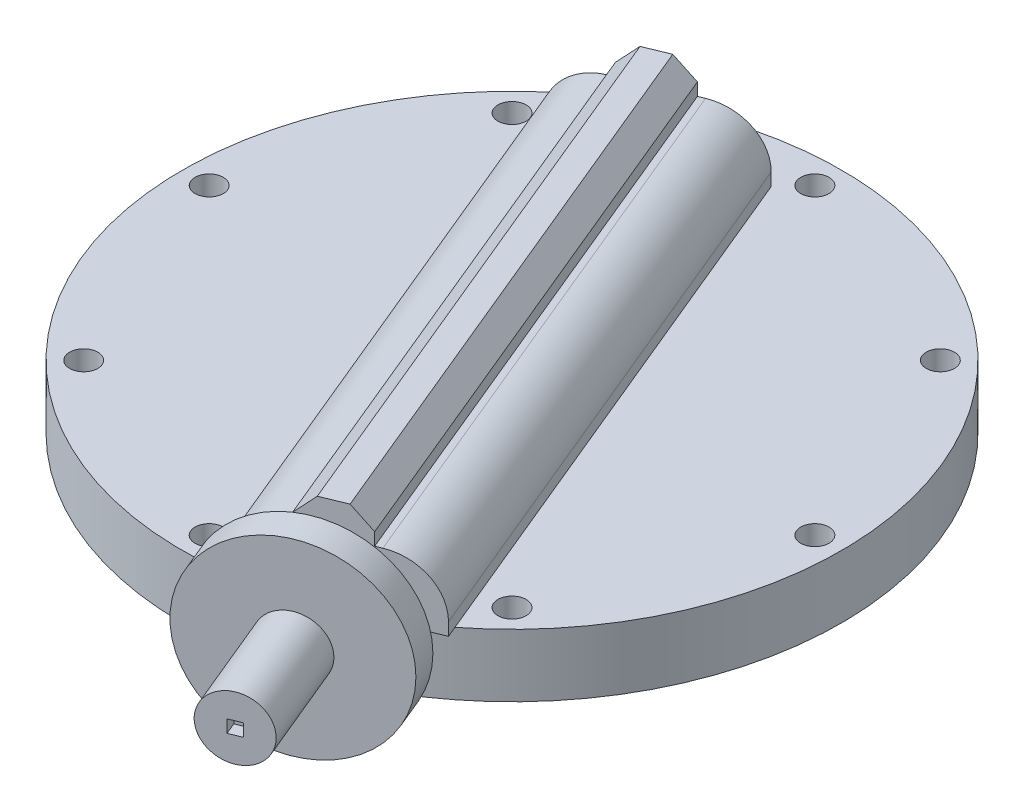
from build123d import *

# Parameters (mm, degrees)
SKETCH1_R           = 66.675
BOSS_EXTRUDE1_DEPTH = 12.7
CUT_EXTRUDE1_START  = -13.7
SKETCH2_R           = 2.8575
CUT_EXTRUDE1_DEPTH  = 14.7
CIRPATTERN1_COUNT   = 8
BOSS_EXTRUDE2_DEPTH = 12.7
BOSS_EXTRUDE3_DEPTH = 6.35
CHAMFER1_SIZE       = 3.81
FILLET3_R           = 10.16
SKETCH7_R           = 10.16
BOSS_EXTRUDE4_DEPTH = 10.16
SKETCH8_R           = 19.05
BOSS_EXTRUDE5_DEPTH = 6.35
SKETCH9_R           = 6.35
BOSS_EXTRUDE6_DEPTH = 21.59
SKETCH11_W          = 2.54
SKETCH11_H          = 2.54
CUT_EXTRUDE2_DEPTH  = 2.54


with BuildPart() as part:
    # Sketch1 → Boss-Extrude1 (new body)
    with BuildSketch(Plane(origin=(0, 0, 0), x_dir=(1, 0, 0), z_dir=(0, 1, 0))):
        Circle(SKETCH1_R)
    extrude(amount=BOSS_EXTRUDE1_DEPTH)

    # Sketch2 → Cut-Extrude1 (cut)
    with BuildSketch(Plane(origin=(0, 12.7, 0), x_dir=(1, 0, 0), z_dir=(0, 1, 0)).offset(CUT_EXTRUDE1_START)):
        with Locations((0, 61.2775)):
            Circle(SKETCH2_R)
    cut_extrude1 = extrude(amount=CUT_EXTRUDE1_DEPTH, mode=Mode.SUBTRACT)

    # CirPattern1: Cut-Extrude1 ×8 about axis
    cirpattern1_axis = Axis((0, 0, 0), (0, 1, 0))
    for i in range(1, CIRPATTERN1_COUNT):
        add(cut_extrude1.rotate(cirpattern1_axis, i * 360 / CIRPATTERN1_COUNT), mode=Mode.SUBTRACT)

    # Sketch4 → Boss-Extrude2 (add)
    with BuildSketch(Plane(origin=(0, 12.7, 0), x_dir=(1, 0, 0), z_dir=(0, 1, 0))):
        Polygon((-37.08191635, 43.06228634), (-4.228760174, 56.670509195), (41.941995941, -54.795556403), (9.088839765, -68.403779258), align=None)
    extrude(amount=BOSS_EXTRUDE2_DEPTH)

    # Sketch5 → Boss-Extrude3 (add)
    with BuildSketch(Plane(origin=(0, 25.4, 0), x_dir=(1, 0, 0), z_dir=(0, 1, 0))):
        Polygon((-26.521973293, 47.436357972), (19.648782821, -64.029707626), (31.382052884, -59.169628035), (-14.78870323, 52.296437563), align=None)
    extrude(amount=BOSS_EXTRUDE3_DEPTH)

    # Chamfer1
    chamfer1_edges = [part.edges().sort_by_distance(p)[0] for p in [
        (-3.436595236, 31.75, 8.296674827),
        (8.296674827, 31.75, 3.436595236),
    ]]
    chamfer(chamfer1_edges, length=CHAMFER1_SIZE)

    # Fillet3
    fillet3_edges = [part.edges().sort_by_distance(p)[0] for p in [
        (18.856617884, 25.4, -0.937476396),
        (-13.996538293, 25.4, 12.670746459),
    ]]
    fillet(fillet3_edges, radius=FILLET3_R)

    # Sketch7 → Boss-Extrude4 (add)
    with BuildSketch(Plane(origin=(28.917473567, 0, 69.812956874), x_dir=(0.923879533, 0, -0.382683432), z_dir=(0.382683432, 0, 0.923879533))):
        with Locations((0, 15.875)):
            Circle(SKETCH7_R)
    extrude(amount=-BOSS_EXTRUDE4_DEPTH)

    # Sketch8 → Boss-Extrude5 (add)
    with BuildSketch(Plane(origin=(28.917473567, 0, 69.812956874), x_dir=(0.923879533, 0, -0.382683432), z_dir=(0.382683432, 0, 0.923879533))):
        with Locations((0, 15.875)):
            Circle(SKETCH8_R)
    extrude(amount=BOSS_EXTRUDE5_DEPTH)

    # Sketch9 → Boss-Extrude6 (add)
    with BuildSketch(Plane(origin=(31.347513362, 0, 75.679591906), x_dir=(0.923879533, 0, -0.382683432), z_dir=(0.382683432, 0, 0.923879533))):
        with Locations((0, 15.875)):
            Circle(SKETCH9_R)
    extrude(amount=BOSS_EXTRUDE6_DEPTH)

    # Sketch11 → Cut-Extrude2 (cut)
    with BuildSketch(Plane(origin=(39.609648667, 0, 95.626151013), x_dir=(0.923879533, 0, -0.382683432), z_dir=(0.382683432, 0, 0.923879533))):
        with Locations((0, 15.875)):
            Rectangle(SKETCH11_W, SKETCH11_H)
    extrude(amount=-CUT_EXTRUDE2_DEPTH, mode=Mode.SUBTRACT)


solid = part.part
